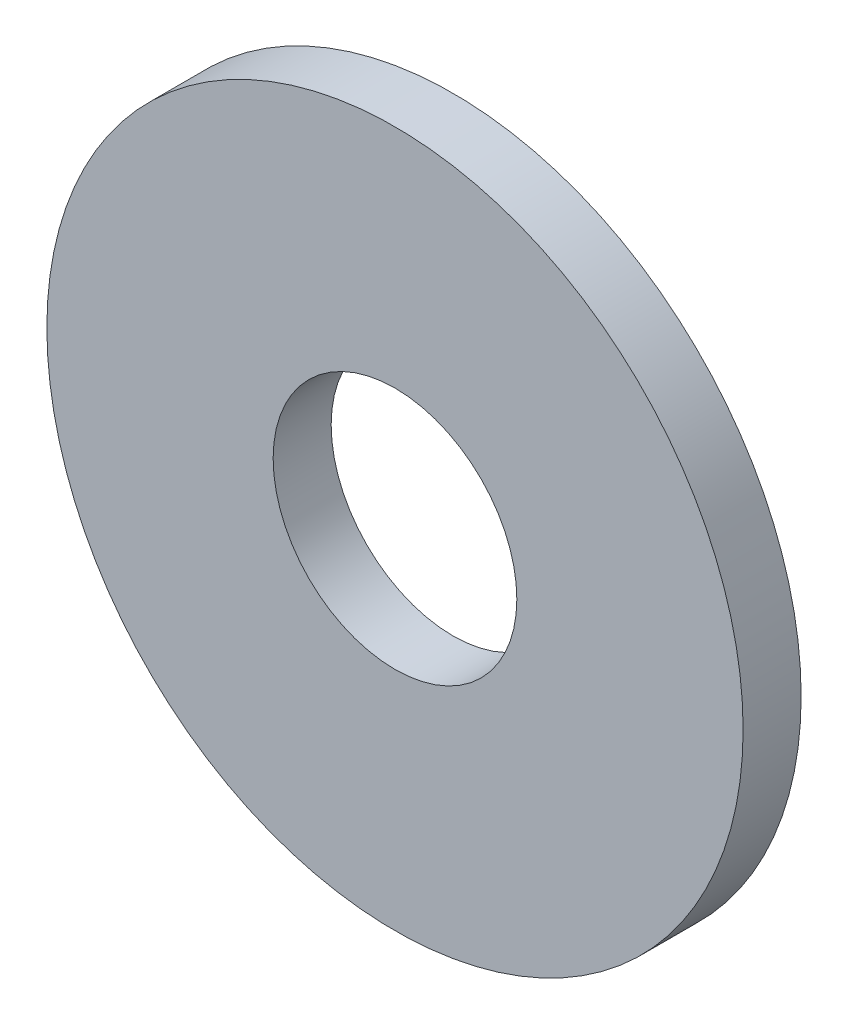
from build123d import *

# Parameters (mm, degrees)
SKETCH2_R           = 15
SKETCH2_R_2         = 5.25
BOSS_EXTRUDE1_DEPTH = 1.25


with BuildPart() as part:
    # Sketch2 → Boss-Extrude1 (new, symmetric)
    with BuildSketch(Plane.XY):
        Circle(SKETCH2_R)
        Circle(SKETCH2_R_2, mode=Mode.SUBTRACT)
    extrude(amount=BOSS_EXTRUDE1_DEPTH, both=True)


solid = part.part
